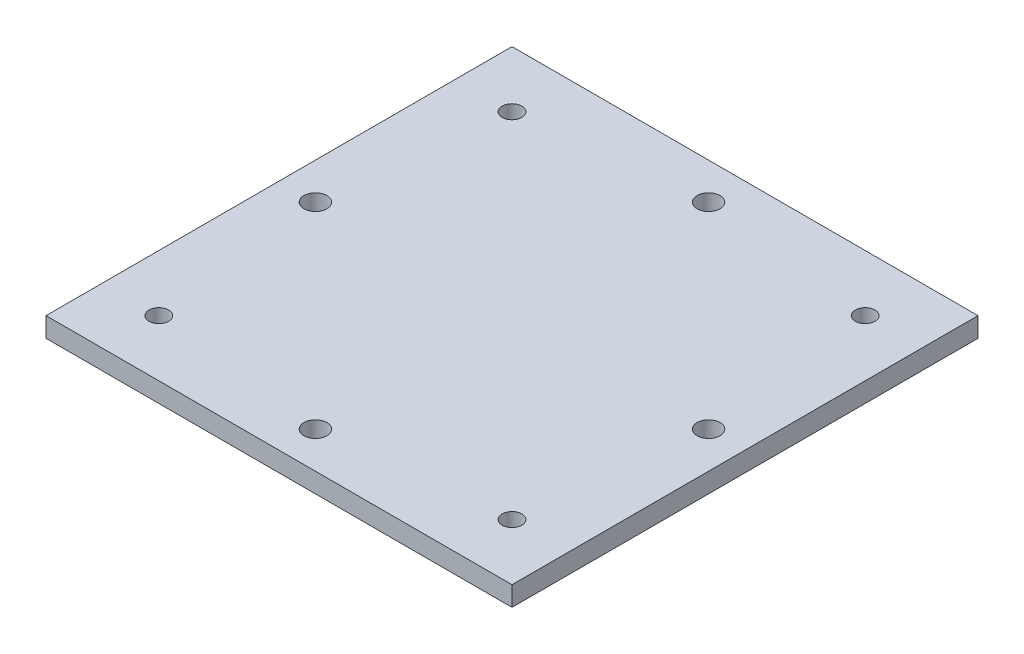
from build123d import *

# Parameters (mm, degrees)
SKETCH2_W           = 71.12
SKETCH2_H           = 71.12
SKETCH2_R           = 1.7526
SKETCH2_R_2         = 1.500000048
BOSS_EXTRUDE1_DEPTH = 3


with BuildPart() as part:
    # Sketch2 → Boss-Extrude1 (new body)
    with BuildSketch(Plane(origin=(0, 0, 0), x_dir=(1, 0, 0), z_dir=(0, 1, 0))):
        Rectangle(SKETCH2_W, SKETCH2_H)
        with Locations((0, 30)):
            Circle(SKETCH2_R, mode=Mode.SUBTRACT)
        with Locations((-30, 0)):
            Circle(SKETCH2_R, mode=Mode.SUBTRACT)
        with Locations((30, 0)):
            Circle(SKETCH2_R, mode=Mode.SUBTRACT)
        with Locations((0, -30)):
            Circle(SKETCH2_R, mode=Mode.SUBTRACT)
        with Locations((26.9494, 26.9494)):
            Circle(SKETCH2_R_2, mode=Mode.SUBTRACT)
        with Locations((-26.9494, 26.9494)):
            Circle(SKETCH2_R_2, mode=Mode.SUBTRACT)
        with Locations((26.9494, -26.9494)):
            Circle(SKETCH2_R_2, mode=Mode.SUBTRACT)
        with Locations((-26.9494, -26.9494)):
            Circle(SKETCH2_R_2, mode=Mode.SUBTRACT)
    extrude(amount=BOSS_EXTRUDE1_DEPTH)


solid = part.part
